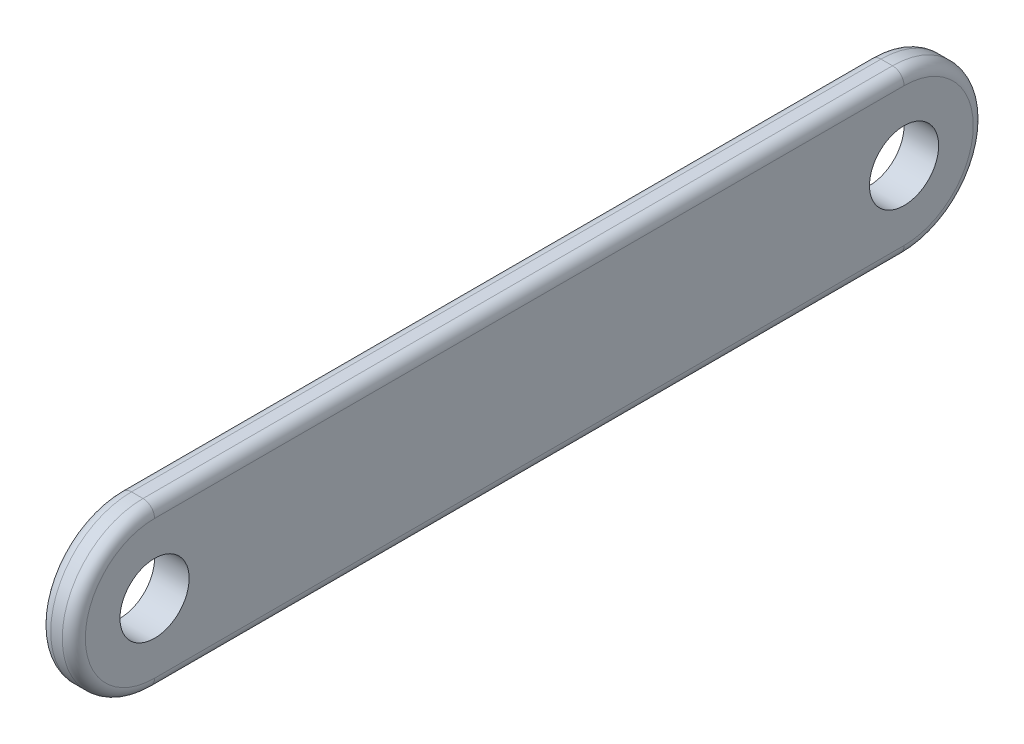
from build123d import *

# Parameters (mm, degrees)
SKETCH_1_R      = 3
EXTRUDE_1_DEPTH = 3
FILLET_1_R      = 1


with BuildPart() as part:
    # 草图1 → 凸台-拉伸1 (new body)
    with BuildSketch(Plane(origin=(0, 0, 0), x_dir=(0, 0, -1), z_dir=(1, 0, 0))):
        with BuildLine():
            Line((-32.5, 7), (32.5, 7))
            ThreePointArc((32.5, 7), (39.5, 0), (32.5, -7))
            Line((32.5, -7), (-32.5, -7))
            ThreePointArc((-32.5, -7), (-39.5, 0), (-32.5, 7))
        make_face()
        with Locations((-32.5, 0)):
            Circle(SKETCH_1_R, mode=Mode.SUBTRACT)
        with Locations((32.5, 0)):
            Circle(SKETCH_1_R, mode=Mode.SUBTRACT)
    extrude(amount=EXTRUDE_1_DEPTH)

    # 圆角1
    fillet_1_edges = [part.edges().sort_by_distance(p)[0] for p in [
        (3, 0, -39.5),
        (3, 7, 0),
        (3, 0, 39.5),
        (0, 7, 0),
        (0, 0, -39.5),
        (0, -7, 0),
        (0, 0, 39.5),
        (3, -7, 0),
    ]]
    fillet(fillet_1_edges, radius=FILLET_1_R)


solid = part.part
